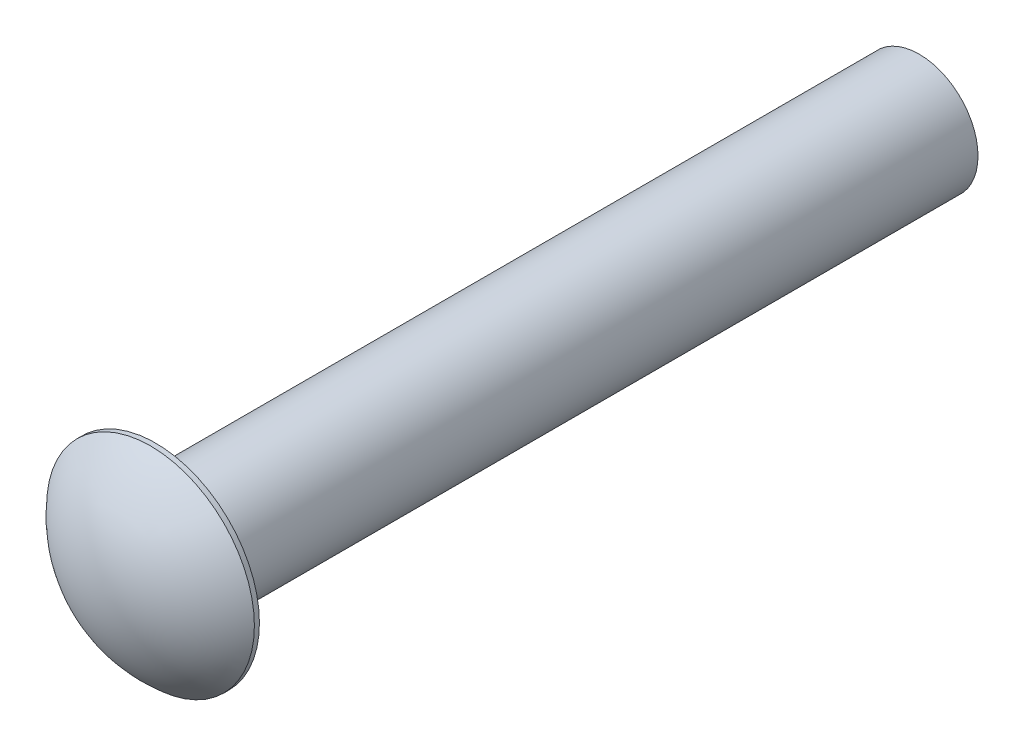
from build123d import *

# Parameters (mm, degrees)
SKETCH1_R           = 1.7272
BOSS_EXTRUDE1_DEPTH = 0.889
SKETCH2_R           = 0.9779
BOSS_EXTRUDE2_DEPTH = 12.7


with BuildPart() as part:
    # Sketch1 → Boss-Extrude1 (new body)
    with BuildSketch(Plane.XY):
        Circle(SKETCH1_R)
    extrude(amount=BOSS_EXTRUDE1_DEPTH)

    # Sketch2 → Boss-Extrude2 (add)
    with BuildSketch(Plane(origin=(0, 0, 0), x_dir=(-1, 0, 0), z_dir=(0, 0, -1))):
        Circle(SKETCH2_R)
    extrude(amount=BOSS_EXTRUDE2_DEPTH)

    # Sketch3 → Cut-Revolve1 (revolve, cut)
    with BuildSketch(Plane(origin=(0, 0, 0), x_dir=(0, 0, -1), z_dir=(1, 0, 0))):
        with BuildLine():
            Line((-0.083738648, 1.7272), (-0.083738648, 2.044683098))
            Line((-0.083738648, 2.044683098), (-1.152680919, 2.044683098))
            Line((-1.152680919, 2.044683098), (-1.187553011, 0))
            Line((-1.187553011, 0), (-0.889000134, 0))
            ThreePointArc((-0.889000134, 0), (-0.67779364, 0.952846512), (-0.083738648, 1.7272))
        make_face()
    revolve(axis=Axis((0, 0, 1.187553011), (0, 0, -1)), mode=Mode.SUBTRACT)


solid = part.part
